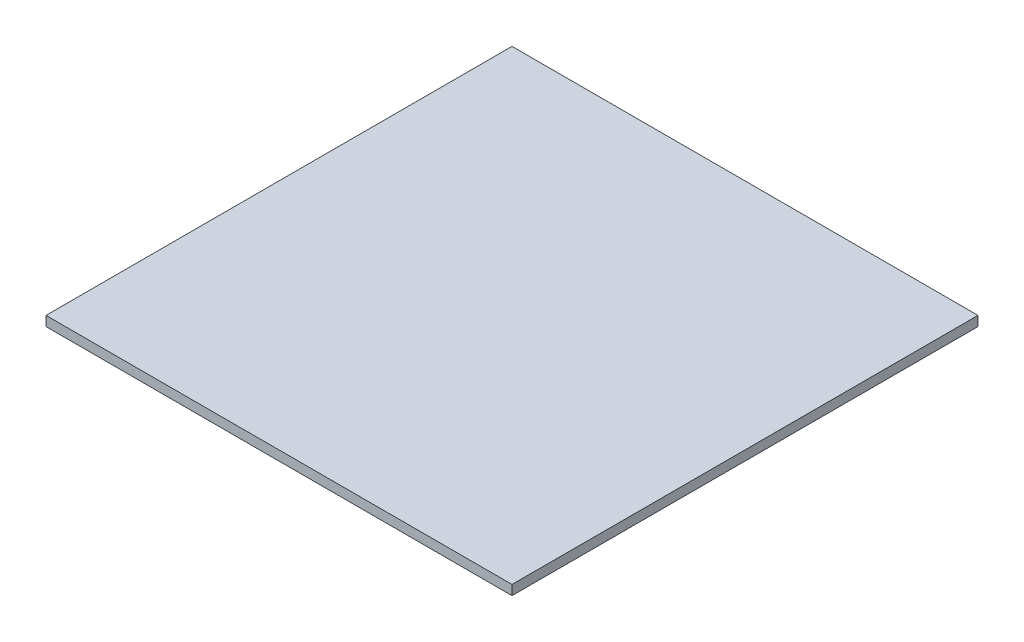
from build123d import *

# Parameters (mm, degrees)
SKETCH1_W           = 240
SKETCH1_H           = 240
BOSS_EXTRUDE1_DEPTH = 5
SKETCH2_R           = 3
CUT_EXTRUDE1_DEPTH  = 2


with BuildPart() as part:
    # Sketch1 → Boss-Extrude1 (new body)
    with BuildSketch(Plane(origin=(0, 180.747129437, 0), x_dir=(1, 0, 0), z_dir=(0, 1, 0))):
        with Locations((-23.70280819, 28.529034587)):
            Rectangle(SKETCH1_W, SKETCH1_H)
    extrude(amount=BOSS_EXTRUDE1_DEPTH)

    # Sketch2 → Cut-Extrude1 (cut)
    with BuildSketch(Plane.XZ.offset(-180.747129437)):
        with Locations((-138.70280819, 86.470965413)):
            Circle(SKETCH2_R)
        with Locations((91.29719181, 86.470965413)):
            Circle(SKETCH2_R)
        with Locations((91.29719181, -143.529034587)):
            Circle(SKETCH2_R)
        with Locations((-138.70280819, -143.529034587)):
            Circle(SKETCH2_R)
    extrude(amount=-CUT_EXTRUDE1_DEPTH, mode=Mode.SUBTRACT)


solid = part.part
